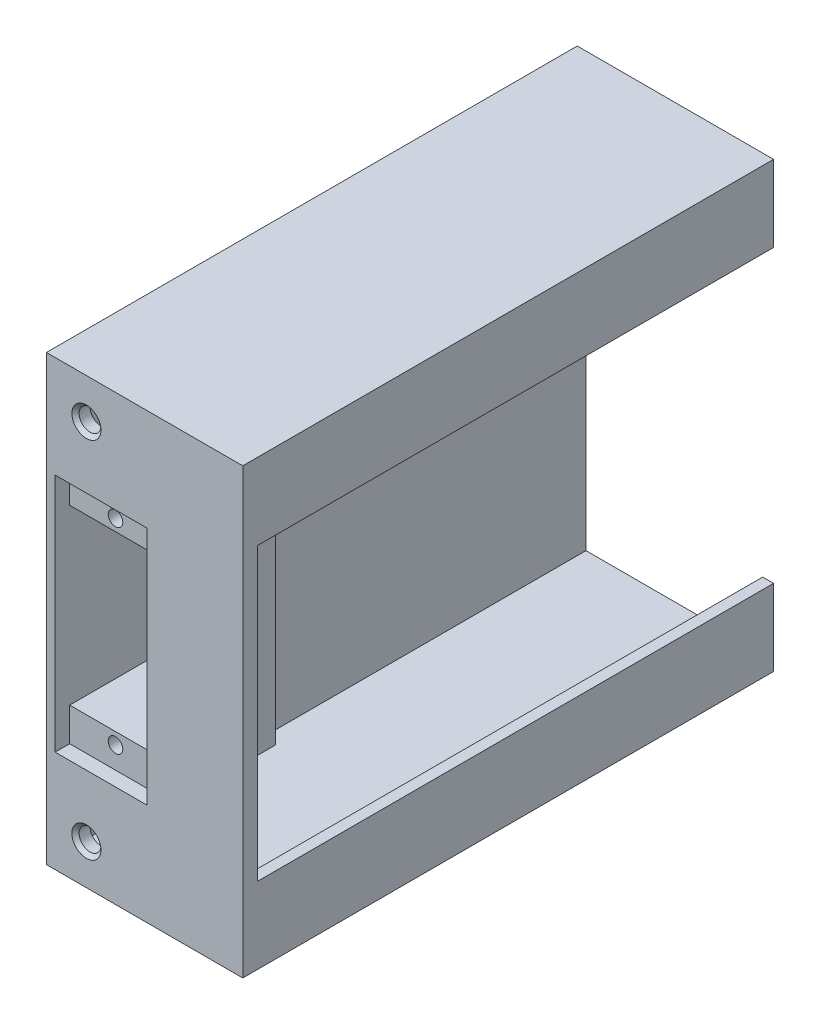
from build123d import *

# Parameters (mm, degrees)
SKETCH_1_W           = 73
SKETCH_1_H           = 61
EXTRUDE_1_DEPTH      = 1.5
SKETCH_3_W           = 73
SKETCH_3_H           = 1.5
EXTRUDE_2_DEPTH      = 24
SKETCH_4_W           = 24
SKETCH_4_H           = 58
EXTRUDE_8_DEPTH      = 2
SKETCH_18_W          = 12
SKETCH_18_H          = 23
CUT_EXTRUDE_10_DEPTH = 2
SKETCH_19_W          = 12
SKETCH_19_H          = 6
EXTRUDE_9_DEPTH      = 15
SKETCH_21_W          = 1
SKETCH_21_H          = 35
EXTRUDE_10_DEPTH     = 15
SKETCH_24_W          = 12
SKETCH_24_H          = 5
CUT_EXTRUDE_12_DEPTH = 2
SKETCH_25_R          = 1
CUT_EXTRUDE_13_DEPTH = 10
SKETCH_28_W          = 73
SKETCH_28_H          = 10.5
EXTRUDE_11_DEPTH     = 1.5
SKETCH_31_W          = 2
SKETCH_31_H          = 40
EXTRUDE_12_DEPTH     = 1.5
SKETCH_32_R          = 1.5
CUT_EXTRUDE_14_DEPTH = 5
CHAMFER_1_SIZE       = 0.5
CHAMFER_2_SIZE       = 0.5
SKETCH_33_W          = 12
SKETCH_33_H          = 23
CUT_EXTRUDE_15_DEPTH = 48
SKETCH_34_W          = 0.3
SKETCH_34_H          = 58
CUT_EXTRUDE_16_DEPTH = 56
SKETCH_35_W          = 0.3
SKETCH_35_H          = 11.5
CUT_EXTRUDE_17_DEPTH = 15
SKETCH_36_W          = 12.6
SKETCH_36_H          = 4.6
CUT_EXTRUDE_18_DEPTH = 2


with BuildPart() as part:
    # 草图1 → 凸台-拉伸1 (new body)
    with BuildSketch(Plane(origin=(0, 0, 0), x_dir=(0, 0, -1), z_dir=(1, 0, 0))):
        Rectangle(SKETCH_1_W, SKETCH_1_H)
    extrude(amount=-EXTRUDE_1_DEPTH)

    # 草图3 → 凸台-拉伸2 (add)
    with BuildSketch(Plane(origin=(0, 0, 0), x_dir=(0, 0, -1), z_dir=(1, 0, 0))):
        with Locations((0, 29.75)):
            Rectangle(SKETCH_3_W, SKETCH_3_H)
        with Locations((0, -29.75)):
            Rectangle(SKETCH_3_W, SKETCH_3_H)
    extrude(amount=EXTRUDE_2_DEPTH)

    # 草图4 → 凸台-拉伸8 (add)
    with BuildSketch(Plane.XY.offset(36.5)):
        with Locations((12, 0)):
            Rectangle(SKETCH_4_W, SKETCH_4_H)
    extrude(amount=-EXTRUDE_8_DEPTH)

    # 草图18 → 切除-拉伸10 (cut)
    with BuildSketch(Plane(origin=(0, 0, 34.5), x_dir=(-1, 0, 0), z_dir=(0, 0, -1))):
        with Locations((-6, 0)):
            Rectangle(SKETCH_18_W, SKETCH_18_H)
    extrude(amount=-CUT_EXTRUDE_10_DEPTH, mode=Mode.SUBTRACT)

    # 草图19 → 凸台-拉伸9 (add)
    with BuildSketch(Plane(origin=(0, 0, 34.5), x_dir=(-1, 0, 0), z_dir=(0, 0, -1))):
        with Locations((-6, 14.5)):
            Rectangle(SKETCH_19_W, SKETCH_19_H)
        with Locations((-6, -14.5)):
            Rectangle(SKETCH_19_W, SKETCH_19_H)
    extrude(amount=EXTRUDE_9_DEPTH)

    # 草图21 → 凸台-拉伸10 (add)
    with BuildSketch(Plane(origin=(0, 0, 34.5), x_dir=(-1, 0, 0), z_dir=(0, 0, -1))):
        with Locations((-12.5, 0)):
            Rectangle(SKETCH_21_W, SKETCH_21_H)
    extrude(amount=EXTRUDE_10_DEPTH)

    # 草图24 → 切除-拉伸12 (cut)
    with BuildSketch(Plane.XY.offset(36.5)):
        with Locations((6, 14)):
            Rectangle(SKETCH_24_W, SKETCH_24_H)
        with Locations((6, -14)):
            Rectangle(SKETCH_24_W, SKETCH_24_H)
    extrude(amount=-CUT_EXTRUDE_12_DEPTH, mode=Mode.SUBTRACT)

    # 草图25 → 切除-拉伸13 (cut)
    with BuildSketch(Plane.XY.offset(34.5)):
        with Locations((6, 13.5)):
            Circle(SKETCH_25_R)
        with Locations((6, -13.5)):
            Circle(SKETCH_25_R)
    extrude(amount=-CUT_EXTRUDE_13_DEPTH, mode=Mode.SUBTRACT)

    # 草图28 → 凸台-拉伸11 (add)
    with BuildSketch(Plane(origin=(24, 0, 0), x_dir=(0, 0, -1), z_dir=(1, 0, 0))):
        with Locations((0, 25.25)):
            Rectangle(SKETCH_28_W, SKETCH_28_H)
        with Locations((0, -25.25)):
            Rectangle(SKETCH_28_W, SKETCH_28_H)
    extrude(amount=EXTRUDE_11_DEPTH)

    # 草图31 → 凸台-拉伸12 (add)
    with BuildSketch(Plane(origin=(24, 0, 0), x_dir=(0, 0, -1), z_dir=(1, 0, 0))):
        with Locations((-35.5, 0)):
            Rectangle(SKETCH_31_W, SKETCH_31_H)
    extrude(amount=EXTRUDE_12_DEPTH)

    # 草图32 → 切除-拉伸14 (cut)
    with BuildSketch(Plane(origin=(0, 0, 34.5), x_dir=(-1, 0, 0), z_dir=(0, 0, -1))):
        with Locations((-4, 25)):
            Circle(SKETCH_32_R)
        with Locations((-4, -25)):
            Circle(SKETCH_32_R)
    extrude(amount=-CUT_EXTRUDE_14_DEPTH, mode=Mode.SUBTRACT)

    # 倒角1
    chamfer_1_edges = [part.edges().sort_by_distance(p)[0] for p in [
        (5.5, 25, 36.5),
    ]]
    chamfer(chamfer_1_edges, length=CHAMFER_1_SIZE)

    # 倒角2
    chamfer_2_edges = [part.edges().sort_by_distance(p)[0] for p in [
        (5.5, -25, 36.5),
    ]]
    chamfer(chamfer_2_edges, length=CHAMFER_2_SIZE)

    # 草图33 → 切除-拉伸15 (cut)
    with BuildSketch(Plane(origin=(0, 0, 19.5), x_dir=(-1, 0, 0), z_dir=(0, 0, -1))):
        Polygon((0, 11.9), (-12.3, 11.9), (-12.3, -11.9), (0, -11.9), (0.3, -11.9), (0.3, 11.9), align=None)
        with Locations((-6, 0)):
            Rectangle(SKETCH_33_W, SKETCH_33_H, mode=Mode.SUBTRACT)
    extrude(amount=-CUT_EXTRUDE_15_DEPTH, mode=Mode.SUBTRACT)

    # 草图34 → 切除-拉伸16 (cut)
    with BuildSketch(Plane(origin=(0, 0, -36.5), x_dir=(-1, 0, 0), z_dir=(0, 0, -1))):
        with Locations((0.15, 0)):
            Rectangle(SKETCH_34_W, SKETCH_34_H)
    extrude(amount=-CUT_EXTRUDE_16_DEPTH, mode=Mode.SUBTRACT)

    # 草图35 → 切除-拉伸17 (cut)
    with BuildSketch(Plane(origin=(0, 0, 19.5), x_dir=(-1, 0, 0), z_dir=(0, 0, -1))):
        with Locations((0.15, 23.25)):
            Rectangle(SKETCH_35_W, SKETCH_35_H)
        with Locations((0.15, -23.25)):
            Rectangle(SKETCH_35_W, SKETCH_35_H)
    extrude(amount=-CUT_EXTRUDE_17_DEPTH, mode=Mode.SUBTRACT)

    # 草图36 → 切除-拉伸18 (cut)
    with BuildSketch(Plane.XY.offset(36.5)):
        with Locations((6, -14.2)):
            Rectangle(SKETCH_36_W, SKETCH_36_H)
        with Locations((6, 14.2)):
            Rectangle(SKETCH_36_W, SKETCH_36_H)
    extrude(amount=-CUT_EXTRUDE_18_DEPTH, mode=Mode.SUBTRACT)


solid = part.part
